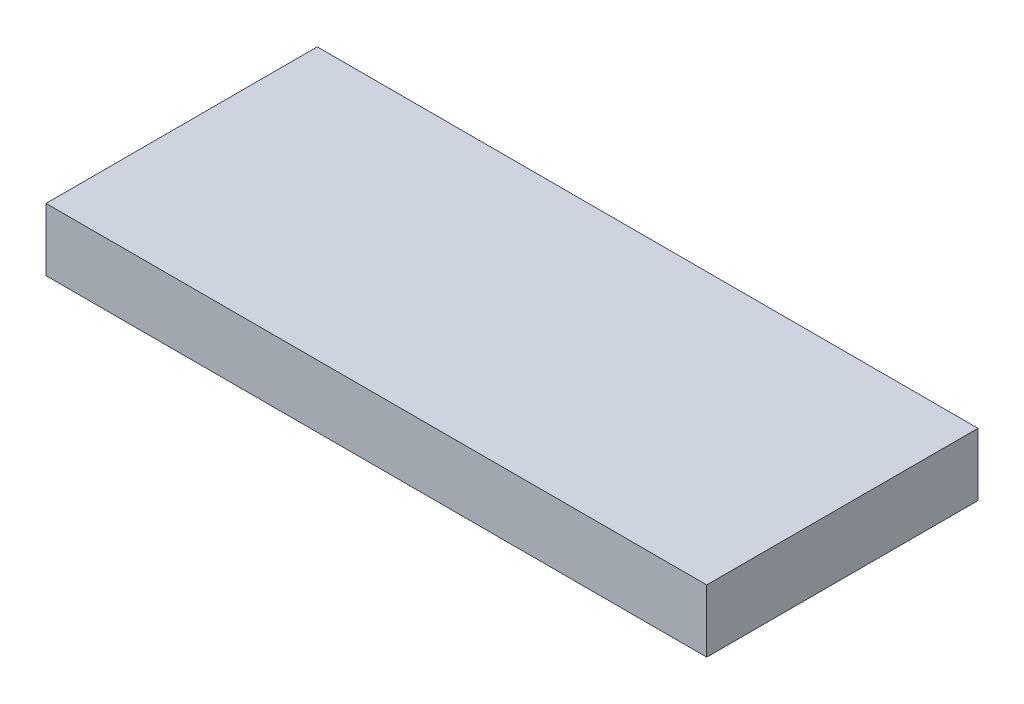
from build123d import *

# Parameters (mm, degrees)
SKETCH1_W           = 47.5
SKETCH1_H           = 19.5
BOSS_EXTRUDE1_DEPTH = 4.5


with BuildPart() as part:
    # Sketch1 → Boss-Extrude1 (new body)
    with BuildSketch(Plane(origin=(0, 0, 0), x_dir=(1, 0, 0), z_dir=(0, 1, 0))):
        Rectangle(SKETCH1_W, SKETCH1_H)
    extrude(amount=BOSS_EXTRUDE1_DEPTH)


solid = part.part
